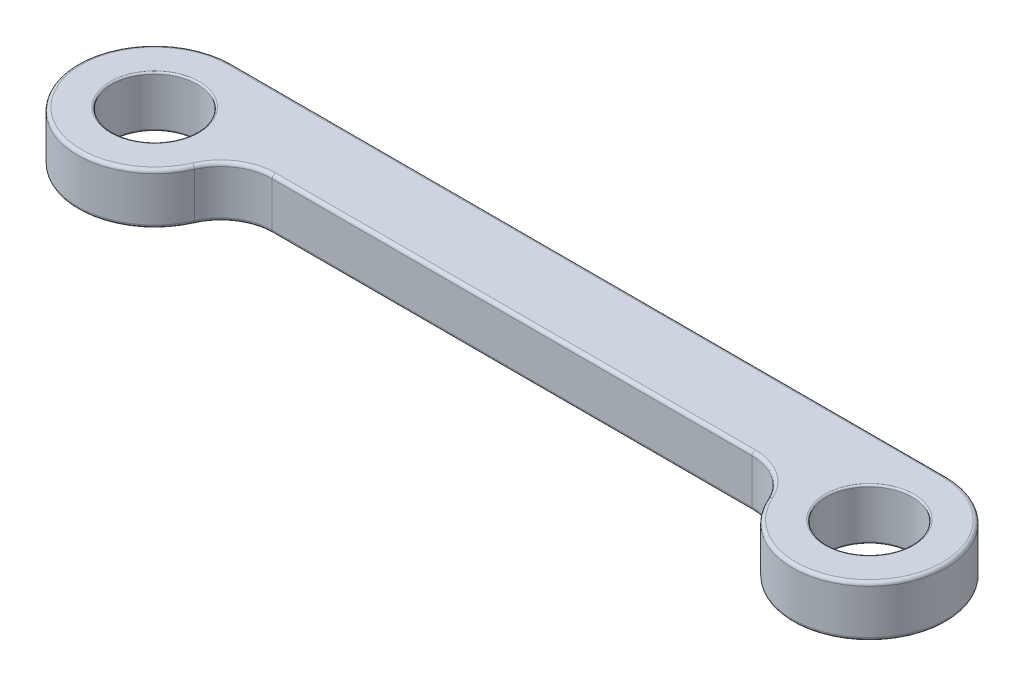
from build123d import *

# Parameters (mm, degrees)
SKETCH_1_R      = 5
EXTRUDE_1_DEPTH = 6
FILLET_1_R      = 0.2
FILLET_2_R      = 0.4


with BuildPart() as part:
    # 草图1 → 凸台-拉伸1 (new body)
    with BuildSketch(Plane(origin=(0, 0, 0), x_dir=(1, 0, 0), z_dir=(0, 1, 0))):
        with BuildLine():
            Line((-41.83, 9), (41.83, 9))
            ThreePointArc((41.83, 9), (49.359940239, -4.929503018), (33.581363749, -3.6))
            ThreePointArc((33.581363749, -3.6), (31.36860826, -0.980039841), (28.082272915, 0))
            Line((28.082272915, 0), (-28.082272915, 0))
            ThreePointArc((-28.082272915, 0), (-31.36860826, -0.980039841), (-33.581363749, -3.6))
            ThreePointArc((-33.581363749, -3.6), (-49.359940239, -4.929503018), (-41.83, 9))
        make_face()
        with Locations((-41.83, 0)):
            Circle(SKETCH_1_R, mode=Mode.SUBTRACT)
        with Locations((41.83, 0)):
            Circle(SKETCH_1_R, mode=Mode.SUBTRACT)
    extrude(amount=EXTRUDE_1_DEPTH)

    # 圆角1
    fillet_1_edges = [part.edges().sort_by_distance(p)[0] for p in [
        (-46.83, 0, 0),
        (-46.83, 6, 0),
        (36.83, 0, 0),
        (36.83, 6, 0),
    ]]
    fillet(fillet_1_edges, radius=FILLET_1_R)

    # 圆角2
    fillet_2_edges = [part.edges().sort_by_distance(p)[0] for p in [
        (0, 6, -9),
        (-49.359940239, 6, 4.929503018),
        (-31.36860826, 6, 0.980039841),
        (0, 6, 0),
        (31.36860826, 6, 0.980039841),
        (0, 0, 0),
        (-31.36860826, 0, 0.980039841),
        (-49.359940239, 0, 4.929503018),
        (0, 0, -9),
        (49.359940239, 0, 4.929503018),
        (31.36860826, 0, 0.980039841),
        (49.359940239, 6, 4.929503018),
    ]]
    fillet(fillet_2_edges, radius=FILLET_2_R)


solid = part.part
